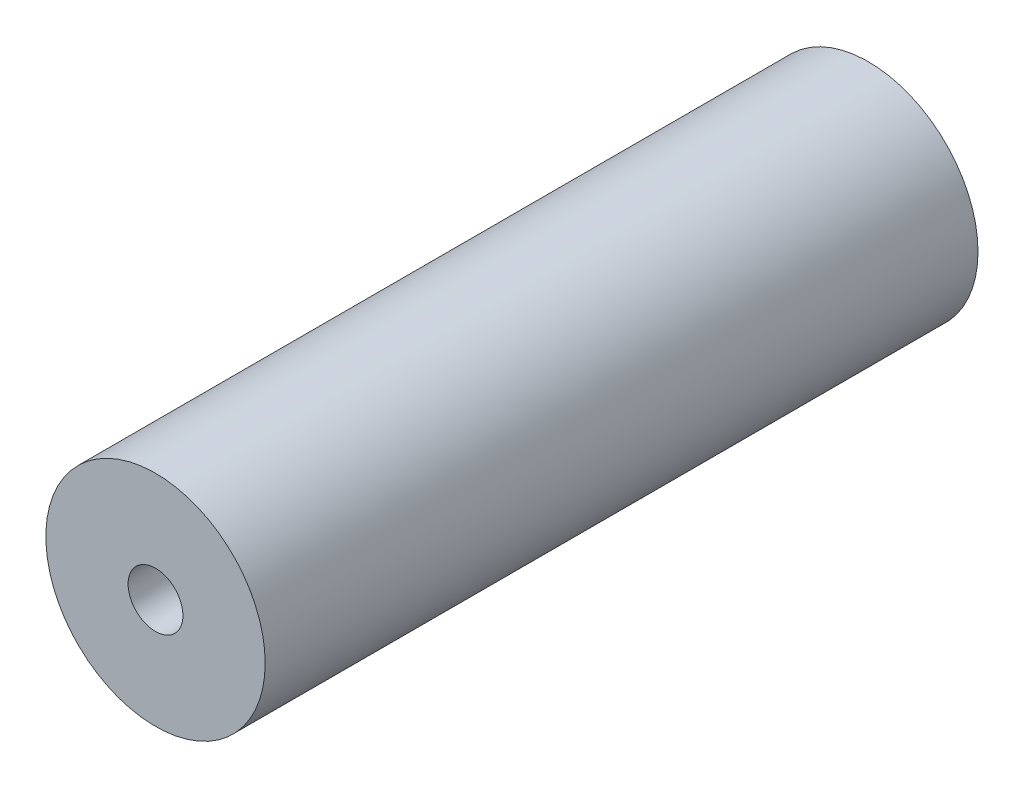
from build123d import *

# Parameters (mm, degrees)
SKETCH1_R           = 25.4
SKETCH1_R_2         = 6.35
BOSS_EXTRUDE1_DEPTH = 165.1


with BuildPart() as part:
    # Sketch1 → Boss-Extrude1 (new body)
    with BuildSketch(Plane.XY):
        Circle(SKETCH1_R)
        Circle(SKETCH1_R_2, mode=Mode.SUBTRACT)
    extrude(amount=BOSS_EXTRUDE1_DEPTH)


solid = part.part
